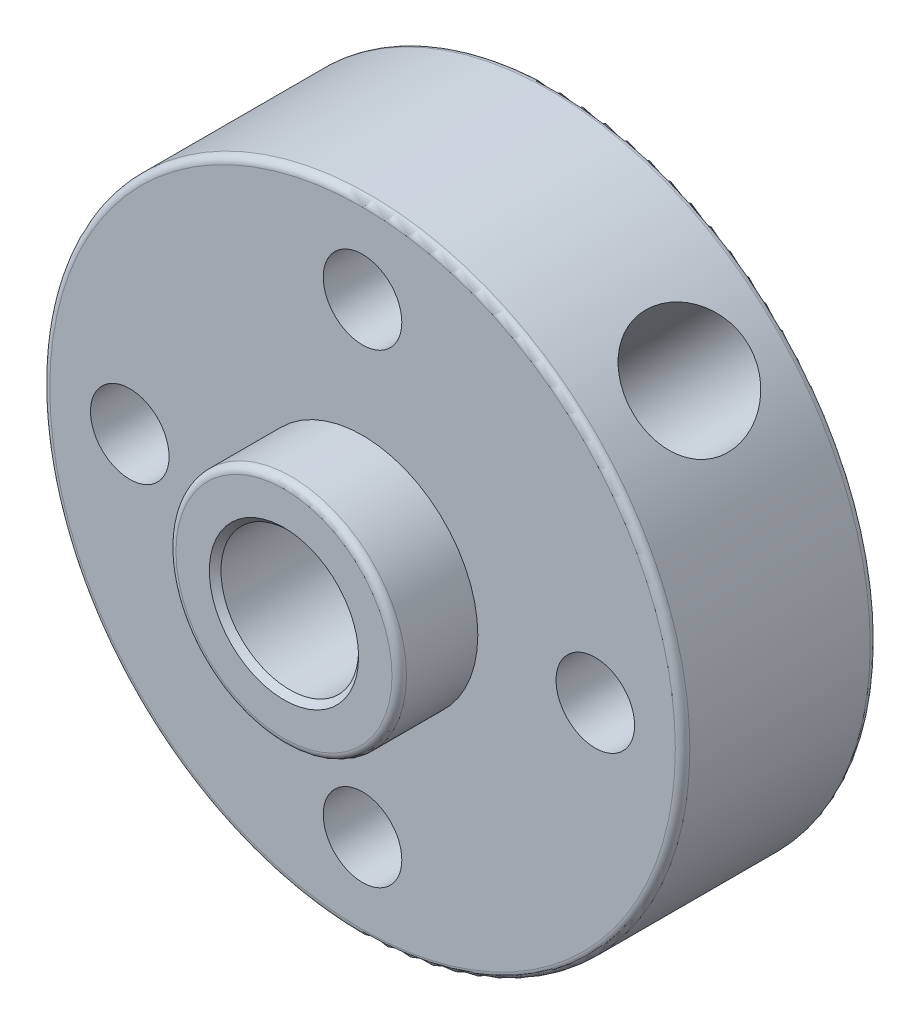
from build123d import *

# Parameters (mm, degrees)
SKETCH1_R           = 11
BOSS_EXTRUDE1_DEPTH = 6.7
SKETCH2_R           = 3.9625
BOSS_EXTRUDE2_DEPTH = 2.7
SKETCH3_R           = 2.365
CUT_EXTRUDE1_DEPTH  = 10.4
SKETCH4_R           = 1.35
CUT_EXTRUDE2_DEPTH  = 7.7
SKETCH6_R           = 2
CUT_EXTRUDE3_DEPTH  = 16.556349186
CHAMFER1_SIZE       = 0.2
FILLET1_R           = 0.25


with BuildPart() as part:
    # Sketch1 → Boss-Extrude1 (new body)
    with BuildSketch(Plane.XY):
        Circle(SKETCH1_R)
    extrude(amount=-BOSS_EXTRUDE1_DEPTH)

    # Sketch2 → Boss-Extrude2 (add)
    with BuildSketch(Plane.XY):
        Circle(SKETCH2_R)
    extrude(amount=BOSS_EXTRUDE2_DEPTH)

    # Sketch3 → Cut-Extrude1 (cut, through all)
    with BuildSketch(Plane.XY.offset(2.7)):
        Circle(SKETCH3_R)
    extrude(amount=-CUT_EXTRUDE1_DEPTH, mode=Mode.SUBTRACT)

    # Sketch4 → Cut-Extrude2 (cut, through all)
    with BuildSketch(Plane.XY):
        with Locations((0, 8)):
            Circle(SKETCH4_R)
        with Locations((8, 0)):
            Circle(SKETCH4_R)
        with Locations((0, -8)):
            Circle(SKETCH4_R)
        with Locations((-8, 0)):
            Circle(SKETCH4_R)
    extrude(amount=-CUT_EXTRUDE2_DEPTH, mode=Mode.SUBTRACT)

    # Sketch6 → Cut-Extrude3 (cut, through all)
    with BuildSketch(Plane(origin=(0, 0, 0), x_dir=(0, 0, 1), z_dir=(-0.707106781, -0.707106781, 0))):
        with Locations((-3.5, 0)):
            Circle(SKETCH6_R)
    extrude(amount=-CUT_EXTRUDE3_DEPTH, mode=Mode.SUBTRACT)

    # Chamfer1
    chamfer1_edges = [part.edges().sort_by_distance(p)[0] for p in [
        (-2.365, 0, -6.7),
        (-2.365, 0, 2.7),
    ]]
    chamfer(chamfer1_edges, length=CHAMFER1_SIZE)

    # Fillet1
    fillet1_edges = [part.edges().sort_by_distance(p)[0] for p in [
        (-11, 0, 0),
        (-11, 0, -6.7),
        (-3.9625, 0, 2.7),
    ]]
    fillet(fillet1_edges, radius=FILLET1_R)


solid = part.part
